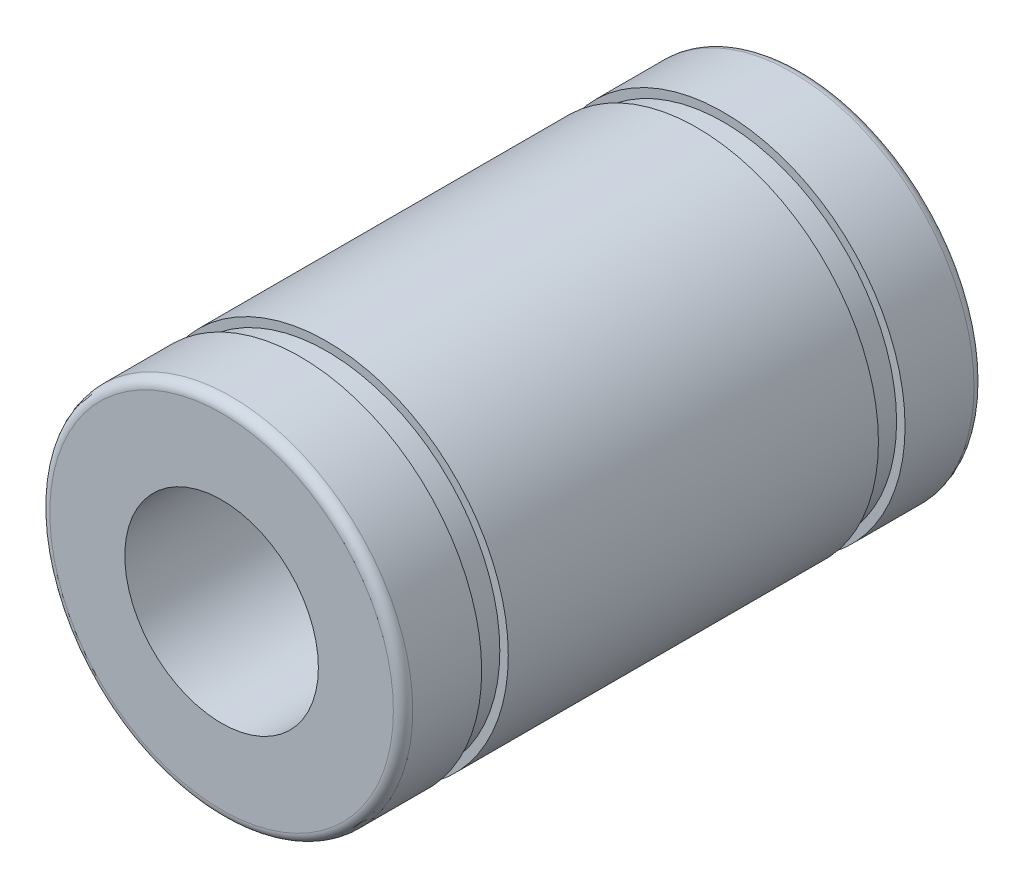
from build123d import *


with BuildPart() as part:
    # Schizzo1 → Rivoluzione1 (revolve)
    with BuildSketch(Plane(origin=(0, 0, 0), x_dir=(1, 0, 0), z_dir=(0, 1, 0))):
        with BuildLine():
            Line((7.1, -3), (4, -3))
            Line((4, -3), (4, -27))
            Line((4, -27), (7.1, -27))
            ThreePointArc((7.1, -27), (7.382842712, -26.882842712), (7.5, -26.6))
            Line((7.5, -26.6), (7.5, -23.75))
            Line((7.5, -23.75), (7.15, -23.75))
            Line((7.15, -23.75), (7.15, -22.65))
            Line((7.15, -22.65), (7.5, -22.65))
            Line((7.5, -22.65), (7.5, -7.35))
            Line((7.5, -7.35), (7.15, -7.35))
            Line((7.15, -7.35), (7.15, -6.25))
            Line((7.15, -6.25), (7.5, -6.25))
            Line((7.5, -6.25), (7.5, -3.4))
            ThreePointArc((7.5, -3.4), (7.382842712, -3.117157288), (7.1, -3))
        make_face()
    revolve(axis=Axis((0, 0, 2.998746006), (0, 0, 1)))


solid = part.part
